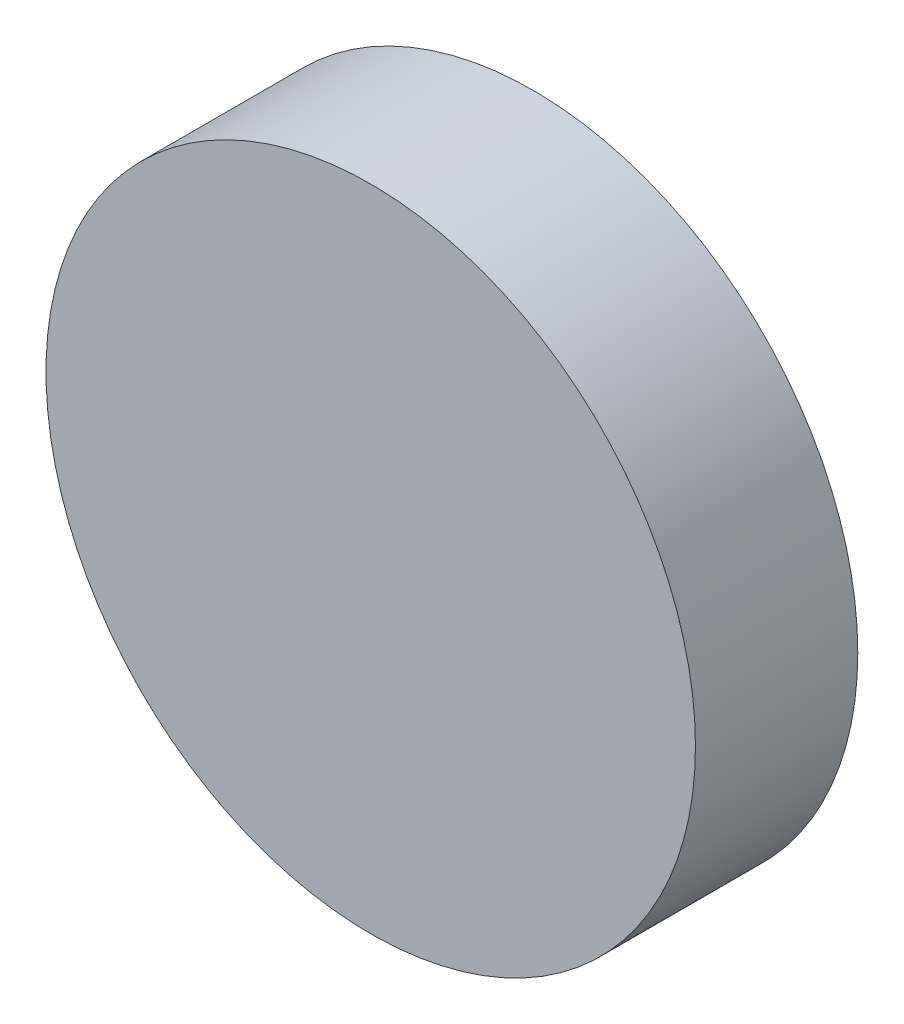
from build123d import *

# Parameters (mm, degrees)
SKETCH1_R           = 50.8
BOSS_EXTRUDE1_DEPTH = 25.4


with BuildPart() as part:
    # Sketch1 → Boss-Extrude1 (new body)
    with BuildSketch(Plane.XY):
        Circle(SKETCH1_R)
    extrude(amount=BOSS_EXTRUDE1_DEPTH)


solid = part.part
